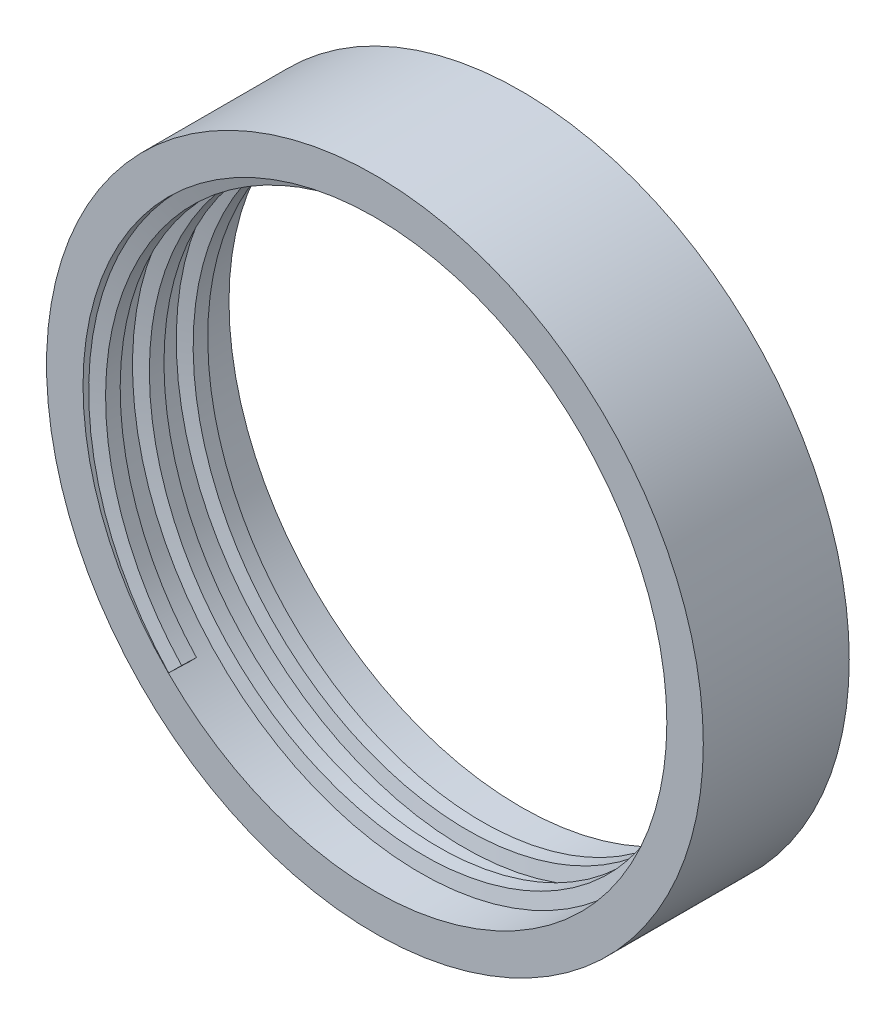
from build123d import *

# Parameters (mm, degrees)
SKETCH_1_R          = 45
SKETCH_1_R_2        = 40
EXTRUDE_1_DEPTH     = 20
SWEEP_1_PITCH       = 6
SWEEP_1_HEIGHT      = 15
SWEEP_1_RADIUS      = 40.15
SWEEP_1_START_ANGLE = -45


with BuildPart() as part:
    # 草图1 → 凸台-拉伸1 (new body)
    with BuildSketch(Plane.XY):
        Circle(SKETCH_1_R)
        Circle(SKETCH_1_R_2, mode=Mode.SUBTRACT)
    extrude(amount=EXTRUDE_1_DEPTH)


with BuildPart() as body_2:
    # 扫描1: sweep along a helix
    with BuildLine() as sweep_1_path:
        add(Helix(SWEEP_1_PITCH, SWEEP_1_HEIGHT, SWEEP_1_RADIUS, center=(0, 0, 18.5), direction=(0, 0, -1), mode=Mode.PRIVATE).rotate(Axis((0, 0, 18.5), (0, 0, -1)), SWEEP_1_START_ANGLE))
    # 草图3 → 扫描1 (sweep)
    with BuildSketch(Plane(origin=(-28.390337265, -28.390337265, 18.5), x_dir=(-0.016813109, 0.016813109, 0.999717279), z_dir=(-0.706906868, 0.706906868, -0.023777327))):
        Polygon((1.5, 0), (-1.5, 0), (-1, 2), (1, 2), align=None)
    sweep(path=sweep_1_path.line, is_frenet=True)


solid = Compound([part.part, body_2.part])
